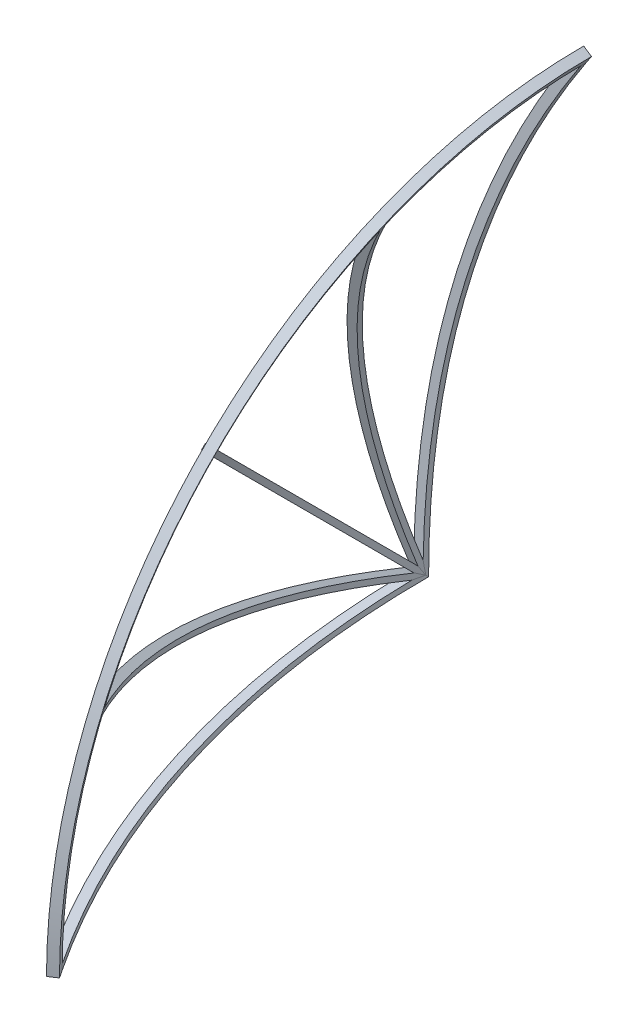
from build123d import *

# Parameters (mm, degrees)
BOSS_EXTRUDE1_DEPTH = 12
CIRPATTERN1_COUNT   = 5
CIRPATTERN1_ANGLE   = 90
CUT_EXTRUDE1_DEPTH  = 1638.380394587


with BuildPart() as part:
    # Sketch2 → Boss-Extrude1 (new body)
    with BuildSketch(Plane.XY):
        with BuildLine():
            Line((0, 0), (20, 0))
            ThreePointArc((20, 0), (105.993208992, 584.258082126), (356.679347003, 1118.962485261))
            Line((356.679347003, 1118.962485261), (340, 1129.998761061))
            ThreePointArc((340, 1129.998761061), (86.841356078, 590.020592861), (0, 0))
        make_face()
    boss_extrude1 = extrude(amount=BOSS_EXTRUDE1_DEPTH)

    # CirPattern1: Boss-Extrude1 ×5 about axis
    cirpattern1_axis = Axis((-103.3895, 6, 6), (1, 0, 0))
    for i in range(1, CIRPATTERN1_COUNT):
        add(boss_extrude1.rotate(cirpattern1_axis, i * CIRPATTERN1_ANGLE / (CIRPATTERN1_COUNT - 1)))

    # Sketch3 → Cut-Extrude1 (cut, through all)
    with BuildSketch(Plane(origin=(0, 0, 0), x_dir=(0, 0, -1), z_dir=(1, 0, 0))):
        Polygon((0, 0), (0, 11.27415685), (5.748633728, 11.27415685), (5.748633728, -8.438156221), (-12.082999297, -8.438156221), (-12, 0), align=None)
    extrude(amount=CUT_EXTRUDE1_DEPTH, mode=Mode.SUBTRACT)

    # Sweep1: sweep along a path in Sketch5
    with BuildLine(Plane(origin=(0, 0, 0), x_dir=(0, 0, -1), z_dir=(1, 0, 0))) as sweep1_path:
        ThreePointArc((0, 1130), (-799.030662741, 799.030662741), (-1130, 0))
    # Sketch4 → Sweep1 (sweep)
    with BuildSketch(Plane(origin=(0, 0, 0), x_dir=(-1, 0, 0), z_dir=(0, 0, -1))):
        Polygon((-340, 1129.998761061), (-356.679347003, 1118.962485261), (-367.715622804, 1135.641832264), (-351.0362758, 1146.678108065), align=None)
    sweep(path=sweep1_path.line)


solid = part.part
